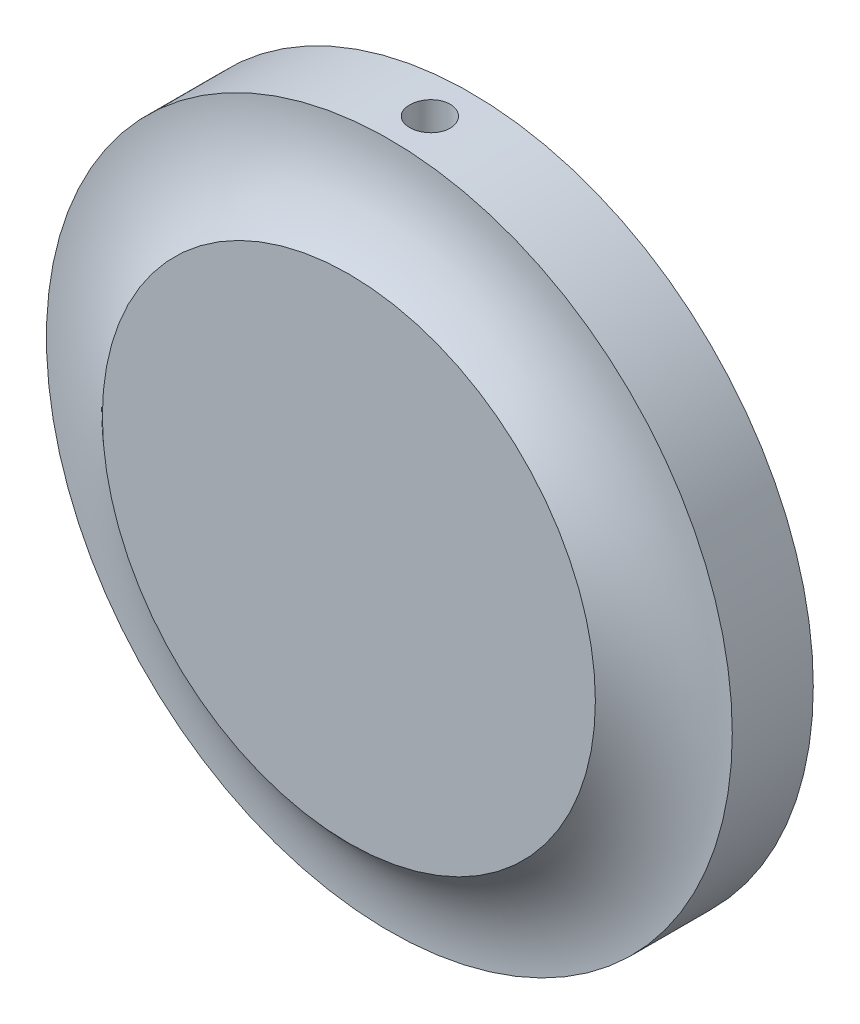
from build123d import *

# Parameters (mm, degrees)
SKETCH1_R           = 25.4
BOSS_EXTRUDE1_DEPTH = 6
SKETCH2_R           = 10
SKETCH3_R           = 1.5
CUT_EXTRUDE1_DEPTH  = 11.4


with BuildPart() as part:
    # Sketch1 → Boss-Extrude1 (new body)
    with BuildSketch(Plane.XY):
        Circle(SKETCH1_R)
    extrude(amount=BOSS_EXTRUDE1_DEPTH)

    # Sketch2 → Cut-Revolve1 (revolve, cut)
    with BuildSketch(Plane(origin=(0, 0, 0), x_dir=(0, 0, -1), z_dir=(1, 0, 0))):
        with Locations((-13, 25.4)):
            Circle(SKETCH2_R)
    revolve(axis=Axis((0, 0, 6), (0, 0, -1)), mode=Mode.SUBTRACT)

    # Mirror1: part across plane


with BuildPart() as part_1:
    add(part.part)
    add(part.part.mirror(Plane.XY))

    # Sketch3 → Cut-Extrude1 (cut, through all)
    with BuildSketch(Plane(origin=(0, 15, 0), x_dir=(1, 0, 0), z_dir=(0, 1, 0))):
        Circle(SKETCH3_R)
    extrude(amount=CUT_EXTRUDE1_DEPTH, mode=Mode.SUBTRACT)


solid = part_1.part
